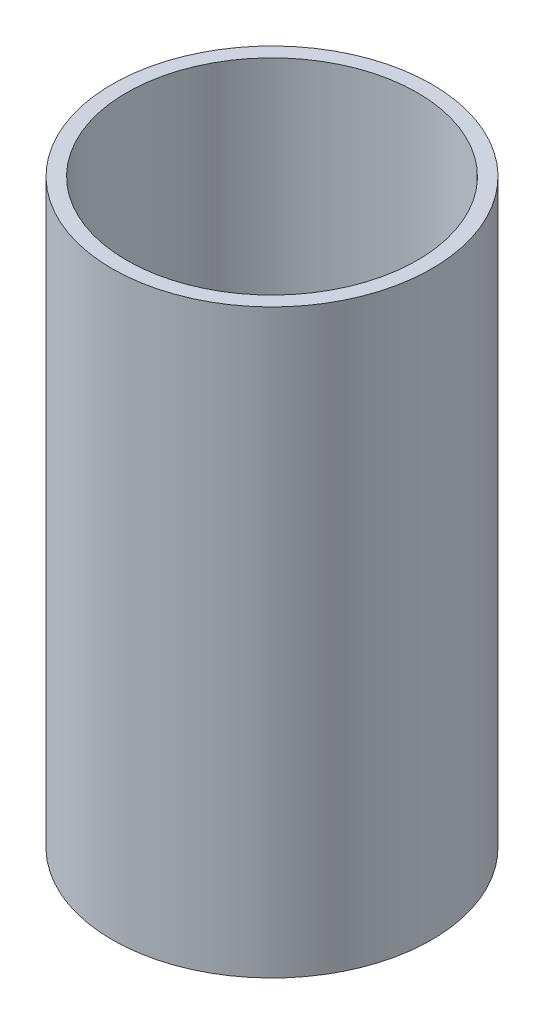
from build123d import *

# Parameters (mm, degrees)
SKETCH1_R           = 33
SKETCH1_R_2         = 30
BOSS_EXTRUDE1_DEPTH = 120


with BuildPart() as part:
    # Sketch1 → Boss-Extrude1 (new body)
    with BuildSketch(Plane(origin=(0, 0, 0), x_dir=(1, 0, 0), z_dir=(0, 1, 0))):
        Circle(SKETCH1_R)
        Circle(SKETCH1_R_2, mode=Mode.SUBTRACT)
    extrude(amount=BOSS_EXTRUDE1_DEPTH)


solid = part.part
